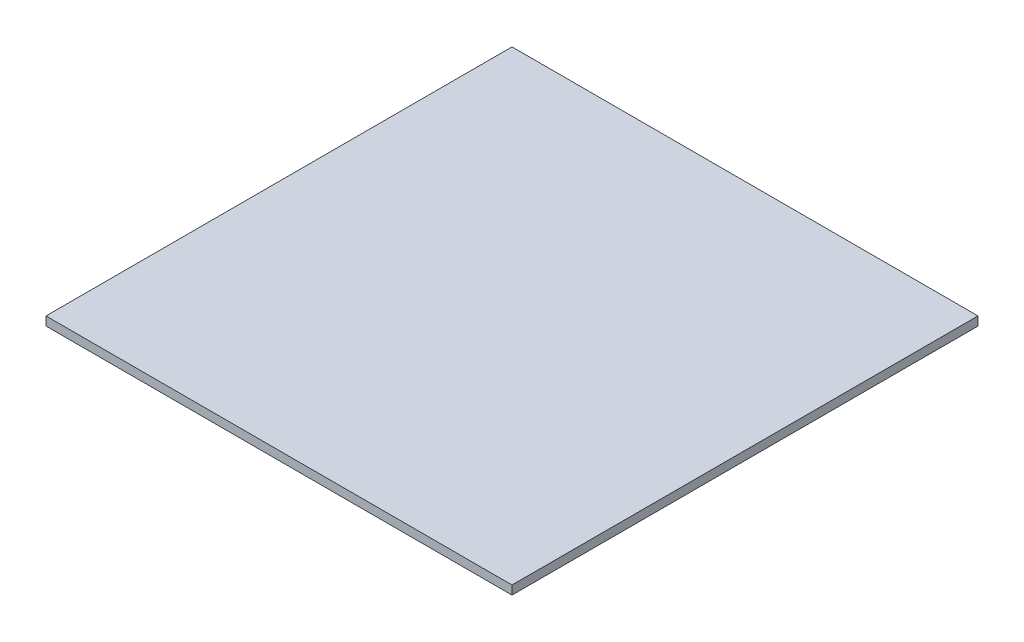
from build123d import *

# Parameters (mm, degrees)
SKETCH1_W           = 530
SKETCH1_H           = 530
BOSS_EXTRUDE1_DEPTH = 10


with BuildPart() as part:
    # Sketch1 → Boss-Extrude1 (new body)
    with BuildSketch(Plane(origin=(0, 0, 0), x_dir=(1, 0, 0), z_dir=(0, 1, 0))):
        Rectangle(SKETCH1_W, SKETCH1_H)
    extrude(amount=BOSS_EXTRUDE1_DEPTH)


solid = part.part
